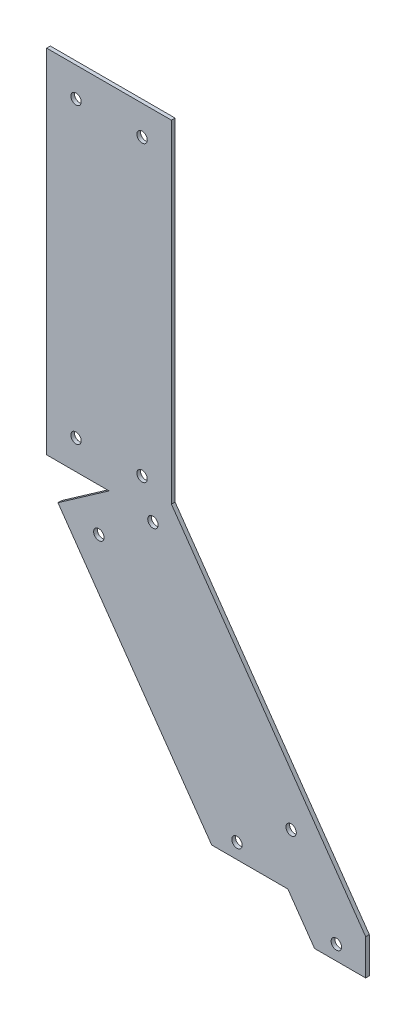
from build123d import *

# Parameters (mm, degrees)
SKETCH1_R           = 2.25
BOSS_EXTRUDE1_DEPTH = 1.5875


with BuildPart() as part:
    # Sketch1 → Boss-Extrude1 (new body)
    with BuildSketch(Plane.XY):
        Polygon((-26.9875, 0), (0, 0), (-22.106865795, -15.479394076), (44.420276683, -110.49), (77.365930897, -110.49), (88.926357353, -127), (111.033223148, -127), (111.033223148, -111.520605924), (26.9875, 8.509126065), (26.9875, 152.4), (-26.9875, 152.4), align=None)
        with Locations((98.333223148, -120.65)):
            Circle(SKETCH1_R, mode=Mode.SUBTRACT)
        with Locations((-14.2875, 12.7)):
            Circle(SKETCH1_R, mode=Mode.SUBTRACT)
        with Locations((-14.2875, 139.7)):
            Circle(SKETCH1_R, mode=Mode.SUBTRACT)
        with Locations((14.2875, 139.7)):
            Circle(SKETCH1_R, mode=Mode.SUBTRACT)
        with Locations((14.2875, 12.7)):
            Circle(SKETCH1_R, mode=Mode.SUBTRACT)
        with Locations((78.77672996, -87.595333778)):
            Circle(SKETCH1_R, mode=Mode.SUBTRACT)
        with Locations((18.988055574, -2.208257628)):
            Circle(SKETCH1_R, mode=Mode.SUBTRACT)
        with Locations((55.369460295, -103.985280447)):
            Circle(SKETCH1_R, mode=Mode.SUBTRACT)
        with Locations((-4.419214091, -18.598204297)):
            Circle(SKETCH1_R, mode=Mode.SUBTRACT)
    extrude(amount=BOSS_EXTRUDE1_DEPTH)


solid = part.part
